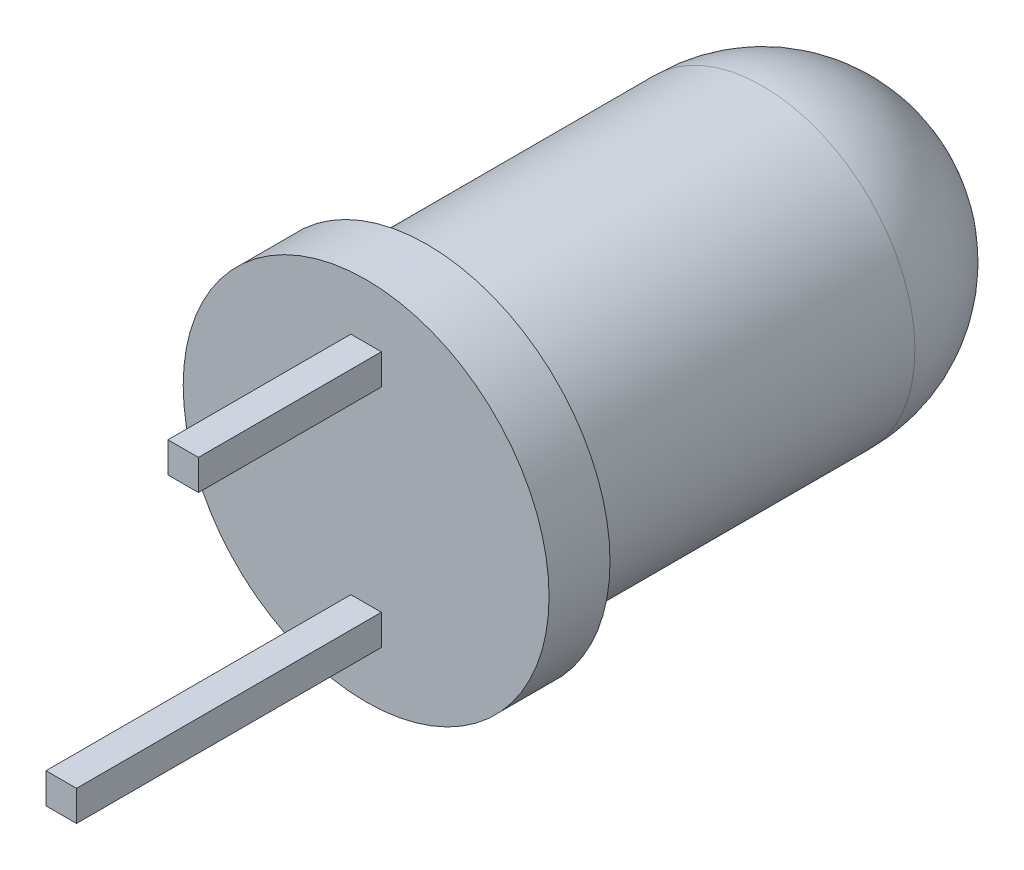
from build123d import *

# Parameters (mm, degrees)
FILLET_1_R        = 2.5
SKETCH_2_W        = 0.5
SKETCH_2_H        = 0.5
EXTRUDE_1_DEPTH   = 3
EXTRUDE_1_2_DEPTH = 3
SKETCH_3_W        = 0.5
SKETCH_3_H        = 0.5
EXTRUDE_2_DEPTH   = 2


with BuildPart() as part:
    # Эскиз1 → Повернуть1 (revolve)
    with BuildSketch(Plane(origin=(0, 0, 0), x_dir=(0, 0, -1), z_dir=(1, 0, 0))):
        Polygon((0, 0), (0, 3), (1, 3), (1, 2.5), (9, 2.5), (9, 0), align=None)
    revolve(axis=Axis((0, 0, -9), (0, 0, 1)))

    # Скругление1
    fillet_1_edges = [part.edges().sort_by_distance(p)[0] for p in [
        (0, -2.5, -9),
    ]]
    fillet(fillet_1_edges, radius=FILLET_1_R)


with BuildPart() as body_2:
    # Эскиз2 → Бобышка-Вытянуть1 (new body)
    with BuildSketch(Plane.XY):
        with Locations((0, -1.85)):
            Rectangle(SKETCH_2_W, SKETCH_2_H)
    extrude(amount=EXTRUDE_1_DEPTH)


with BuildPart() as body_3:
    # Эскиз2 → Extrude 1 2 (new body)
    with BuildSketch(Plane.XY):
        with Locations((0, 1.85)):
            Rectangle(SKETCH_2_W, SKETCH_2_H)
    extrude(amount=EXTRUDE_1_2_DEPTH)


with BuildPart() as body_4:
    # Эскиз3 → Бобышка-Вытянуть2 (new body)
    with BuildSketch(Plane.XY.offset(3)):
        with Locations((0, -1.85)):
            Rectangle(SKETCH_3_W, SKETCH_3_H)
    extrude(amount=EXTRUDE_2_DEPTH)


with BuildPart() as body_2_1:
    add(body_2.part)

    # Combine 1: union body 4
    add(body_4.part)


solid = Compound([part.part, body_3.part, body_2_1.part])
